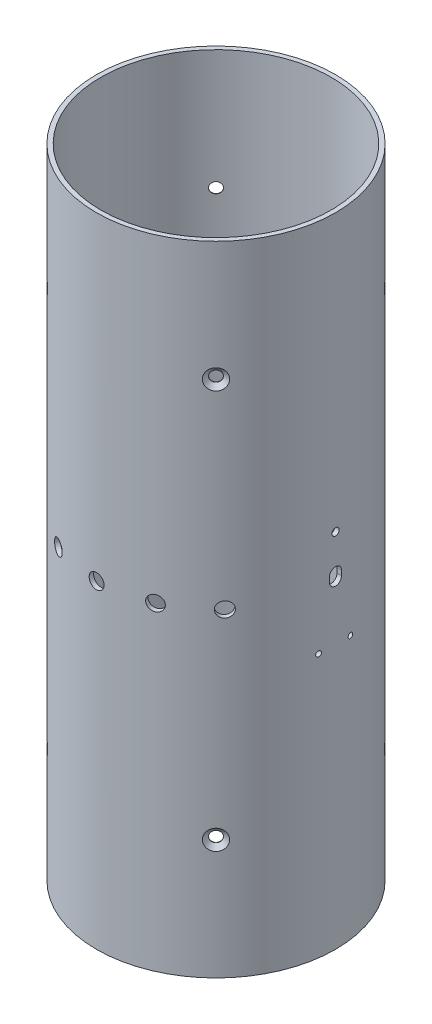
from build123d import *

# Parameters (mm, degrees)
COUPLER_PROFILE_R                           = 76.1746
COUPLER_PROFILE_R_2                         = 73.3425
COUPLER_BODY_DEPTH                          = 406.4
CSK_FOR_1_4_FLAT_HEAD_MACHINE_SCREW_2_COUNT = 2
CSK_FOR_1_4_FLAT_HEAD_MACHINE_SCREW_2_PITCH = 254
CIRPATTERN2_COUNT                           = 4
F_3_8_0_375_DIAMETER_HOLE1_REACH            = 442.652
F_3_8_0_375_DIAMETER_HOLE1_BORE_R           = 4.7625
CIRPATTERN3_COUNT                           = 3
CIRPATTERN3_ANGLE                           = 48
CIRPATTERN3_THE_OTHER_WAY_COUNT             = 3
CIRPATTERN3_THE_OTHER_WAY_ANGLE             = 48
CUT_EXTRUDE2_REACH                          = 442.652
CUT_EXTRUDE2_END_RADIUS                     = 73.3425
SKETCH10_R                                  = 1.651
SKETCH10_R_2                                = 2.286
CUT_EXTRUDE4_REACH                          = 442.652
CUT_EXTRUDE4_END_RADIUS                     = 73.3425


with BuildPart() as part:
    # Coupler Profile → Coupler Body (new body)
    with BuildSketch(Plane(origin=(0, 0, 0), x_dir=(1, 0, 0), z_dir=(0, 1, 0))):
        with Locations(Location((0, 0, 0), (0, 0, 270))):
            Circle(COUPLER_PROFILE_R)
        with Locations(Location((0, 0, 0), (0, 0, 270))):
            Circle(COUPLER_PROFILE_R_2, mode=Mode.SUBTRACT)
    extrude(amount=COUPLER_BODY_DEPTH)

    # Sketch7 → CSK for 1/4 Flat Head Machine Screw (100)1 (revolve, cut)
    with BuildSketch(Plane(origin=(-53.863576214, 76.2, 53.863576214), x_dir=(0.7071067811865464, 0, 0.7071067811865488), z_dir=(0, 1, 0))):
        Polygon((0, 0), (0, 6.855827343), (3.3782, 4.826), (3.3782, 2.568232241), (6.4389, 0), align=None)
    csk_for_1_4_flat_head_machine_screw_100 = revolve(axis=Axis((-58.353704275, 76.2, 58.353704275), (0.7071067811865487, 0, -0.7071067811865465)), mode=Mode.SUBTRACT)

    # CSK for 1_4 Flat Head Machine Screw  2: CSK for 1/4 Flat Head Machine Screw (100)1 ×2
    with Locations(*[(0, i * CSK_FOR_1_4_FLAT_HEAD_MACHINE_SCREW_2_PITCH, 0) for i in range(1, CSK_FOR_1_4_FLAT_HEAD_MACHINE_SCREW_2_COUNT)]):
        add(csk_for_1_4_flat_head_machine_screw_100, mode=Mode.SUBTRACT)

    # CirPattern2: CSK for 1/4 Flat Head Machine Screw (100)1 ×4 about axis
    cirpattern2_axis = Axis((0, 406.4, 0), (0, 1, 0))
    for i in range(1, CIRPATTERN2_COUNT):
        add(csk_for_1_4_flat_head_machine_screw_100.rotate(cirpattern2_axis, i * 360 / CIRPATTERN2_COUNT), mode=Mode.SUBTRACT)

    # CirPattern2 copy 1 sketch → CirPattern2 copy 1 (revolve, cut)
    with BuildSketch(Plane(origin=(53.863576214, 330.2, 53.863576214), x_dir=(0.7071067811865488, 0, -0.7071067811865464), z_dir=(0, 1, 0))):
        Polygon((0, 0), (0, 6.855827343), (3.3782, 4.826), (3.3782, 2.568232241), (6.4389, 0), align=None)
    revolve(axis=Axis((58.353704275, 330.2, 58.353704275), (-0.7071067811865465, 0, -0.7071067811865487)), mode=Mode.SUBTRACT)

    # CirPattern2 copy 2 sketch → CirPattern2 copy 2 (revolve, cut)
    with BuildSketch(Plane(origin=(53.863576214, 330.2, -53.863576214), x_dir=(-0.7071067811865462, 0, -0.7071067811865489), z_dir=(0, 1, 0))):
        Polygon((0, 0), (0, 6.855827343), (3.3782, 4.826), (3.3782, 2.568232241), (6.4389, 0), align=None)
    revolve(axis=Axis((58.353704275, 330.2, -58.353704275), (-0.7071067811865488, 0, 0.7071067811865464)), mode=Mode.SUBTRACT)

    # CirPattern2 copy 3 sketch → CirPattern2 copy 3 (revolve, cut)
    with BuildSketch(Plane(origin=(-53.863576214, 330.2, -53.863576214), x_dir=(-0.7071067811865489, 0, 0.7071067811865462), z_dir=(0, 1, 0))):
        Polygon((0, 0), (0, 6.855827343), (3.3782, 4.826), (3.3782, 2.568232241), (6.4389, 0), align=None)
    revolve(axis=Axis((-58.353704275, 330.2, -58.353704275), (0.7071067811865464, 0, 0.7071067811865488)), mode=Mode.SUBTRACT)

    # 3/8 (0.375) Diameter Hole1 bore → 3/8 (0.375) Diameter Hole1 (cut, up to next)
    with BuildSketch(Plane.XY.offset(76.1746), mode=Mode.PRIVATE) as f_3_8_0_375_diameter_hole1_sk1:
        with Locations((0, 203.2)):
            Circle(F_3_8_0_375_DIAMETER_HOLE1_BORE_R)
    f_3_8_0_375_diameter_hole1_tool1 = extrude(f_3_8_0_375_diameter_hole1_sk1.sketch, amount=-F_3_8_0_375_DIAMETER_HOLE1_REACH, mode=Mode.PRIVATE) & part.part
    f_3_8_0_375_diameter_hole1 = f_3_8_0_375_diameter_hole1_tool1.solids().sort_by_distance((0, 203.2, 76.1746))[0]
    add(f_3_8_0_375_diameter_hole1, mode=Mode.SUBTRACT)

    # CirPattern3: 3/8 (0.375) Diameter Hole1 ×3 about axis
    cirpattern3_axis = Axis((0, 406.4, 0), (0, 1, 0))
    for i in range(1, CIRPATTERN3_COUNT):
        add(f_3_8_0_375_diameter_hole1.rotate(cirpattern3_axis, i * CIRPATTERN3_ANGLE / (CIRPATTERN3_COUNT - 1)), mode=Mode.SUBTRACT)

    # CirPattern3 the other way: 3/8 (0.375) Diameter Hole1 ×3 about axis
    cirpattern3_the_other_way_axis = Axis((0, 406.4, 0), (0, -1, 0))
    for i in range(1, CIRPATTERN3_THE_OTHER_WAY_COUNT):
        add(f_3_8_0_375_diameter_hole1.rotate(cirpattern3_the_other_way_axis, i * CIRPATTERN3_THE_OTHER_WAY_ANGLE / (CIRPATTERN3_THE_OTHER_WAY_COUNT - 1)), mode=Mode.SUBTRACT)

    # Cut-Extrude2: up to this cylinder (the profile starts outside it)
    cut_extrude2_end = Plane(origin=(0, 199.058948, 0), z_dir=(0, -1, 0)) * Cylinder(CUT_EXTRUDE2_END_RADIUS, 1095.570886, mode=Mode.PRIVATE)
    # Sketch10 → Cut-Extrude2 (cut, up to the surface)
    with BuildSketch(Plane(origin=(76.1746, 0, 0), x_dir=(0, 0, -1), z_dir=(1, 0, 0)), mode=Mode.PRIVATE) as cut_extrude2_sk1:
        with Locations((-10.139493564, 167.768005332)):
            Circle(SKETCH10_R)
    cut_extrude2_tool1 = extrude(cut_extrude2_sk1.sketch, amount=-CUT_EXTRUDE2_REACH, mode=Mode.PRIVATE) - cut_extrude2_end
    add(cut_extrude2_tool1.solids().sort_by_distance((76.1746, 167.768005, 10.139494))[0], mode=Mode.SUBTRACT)
    # Sketch10 → Cut-Extrude2 (cut, up to the surface)
    with BuildSketch(Plane(origin=(76.1746, 0, 0), x_dir=(0, 0, -1), z_dir=(1, 0, 0)), mode=Mode.PRIVATE) as cut_extrude2_sk2:
        with Locations((10.139493564, 167.768005332)):
            Circle(SKETCH10_R)
    cut_extrude2_tool2 = extrude(cut_extrude2_sk2.sketch, amount=-CUT_EXTRUDE2_REACH, mode=Mode.PRIVATE) - cut_extrude2_end
    add(cut_extrude2_tool2.solids().sort_by_distance((76.1746, 167.768005, -10.139494))[0], mode=Mode.SUBTRACT)
    # Sketch10 → Cut-Extrude2 (cut, up to the surface)
    with BuildSketch(Plane(origin=(76.1746, 0, 0), x_dir=(0, 0, -1), z_dir=(1, 0, 0)), mode=Mode.PRIVATE) as cut_extrude2_sk3:
        with Locations((0, 230.34989109)):
            Circle(SKETCH10_R_2)
    cut_extrude2_tool3 = extrude(cut_extrude2_sk3.sketch, amount=-CUT_EXTRUDE2_REACH, mode=Mode.PRIVATE) - cut_extrude2_end
    add(cut_extrude2_tool3.solids().sort_by_distance((76.1746, 230.349891, 0))[0], mode=Mode.SUBTRACT)

    # Cut-Extrude4: up to this cylinder (the profile starts outside it)
    cut_extrude4_end = Plane(origin=(0, 205.785801, 0), z_dir=(0, -1, 0)) * Cylinder(CUT_EXTRUDE4_END_RADIUS, 1032.989, mode=Mode.PRIVATE)
    # Sketch11 → Cut-Extrude4 (cut, up to the surface)
    with BuildSketch(Plane(origin=(76.1746, 0, 0), x_dir=(0, 0, -1), z_dir=(1, 0, 0)), mode=Mode.PRIVATE) as cut_extrude4_sk1:
        with BuildLine():
            Line((-3.81, 207.337587864), (-3.81, 204.234014442))
            ThreePointArc((-3.81, 204.234014442), (0, 200.424014442), (3.81, 204.234014442))
            Line((3.81, 204.234014442), (3.81, 207.337587864))
            ThreePointArc((3.81, 207.337587864), (0, 211.147587864), (-3.81, 207.337587864))
        make_face()
    cut_extrude4_tool1 = extrude(cut_extrude4_sk1.sketch, amount=-CUT_EXTRUDE4_REACH, mode=Mode.PRIVATE) - cut_extrude4_end
    add(cut_extrude4_tool1.solids().sort_by_distance((76.1746, 205.785801, 0))[0], mode=Mode.SUBTRACT)


solid = part.part
